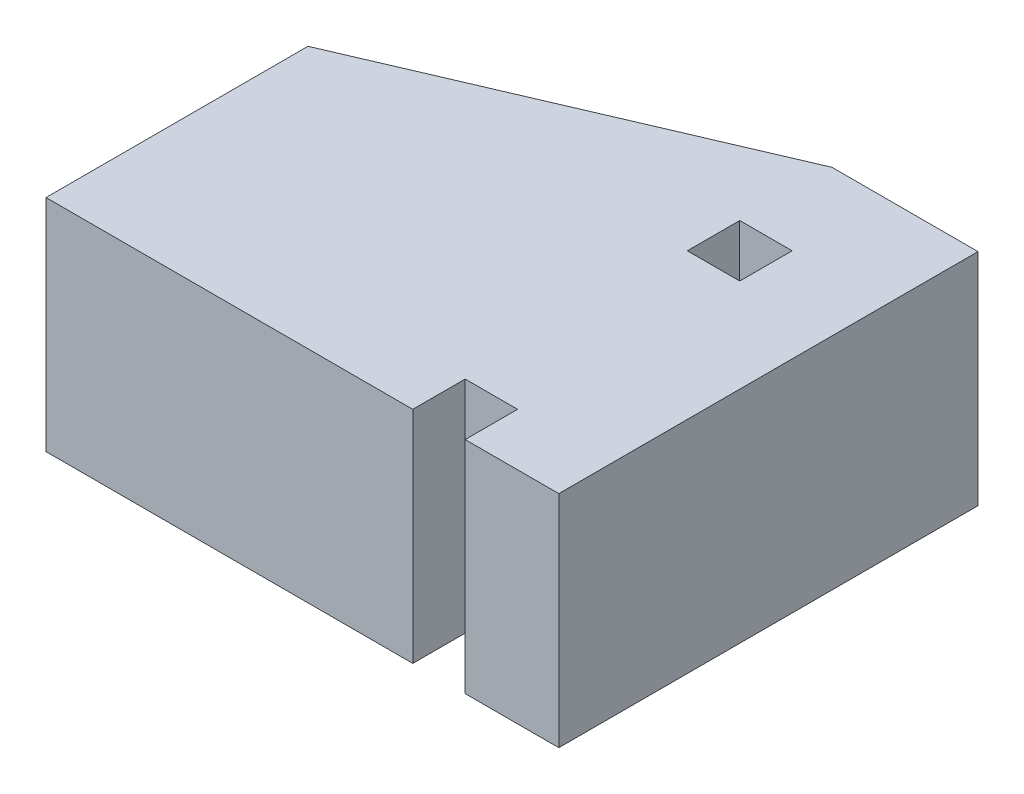
from build123d import *

# Parameters (mm, degrees)
ESQUISSE1_W        = 10
ESQUISSE1_H        = 10
BOSS_EXTRU_1_DEPTH = 42


with BuildPart() as part:
    # Esquisse1 → Boss.-Extru.1 (new body)
    with BuildSketch(Plane(origin=(0, 0, 0), x_dir=(1, 0, 0), z_dir=(0, 1, 0))):
        Polygon((0, -21.2), (0, -31.2), (17.87, -31.2), (17.87, 48.8), (-10, 48.8), (-80, 18.8), (-80, -31.2), (-10, -31.2), (-10, -21.2), align=None)
        with Locations((-5, 26.2)):
            Rectangle(ESQUISSE1_W, ESQUISSE1_H, mode=Mode.SUBTRACT)
    extrude(amount=BOSS_EXTRU_1_DEPTH)


solid = part.part
